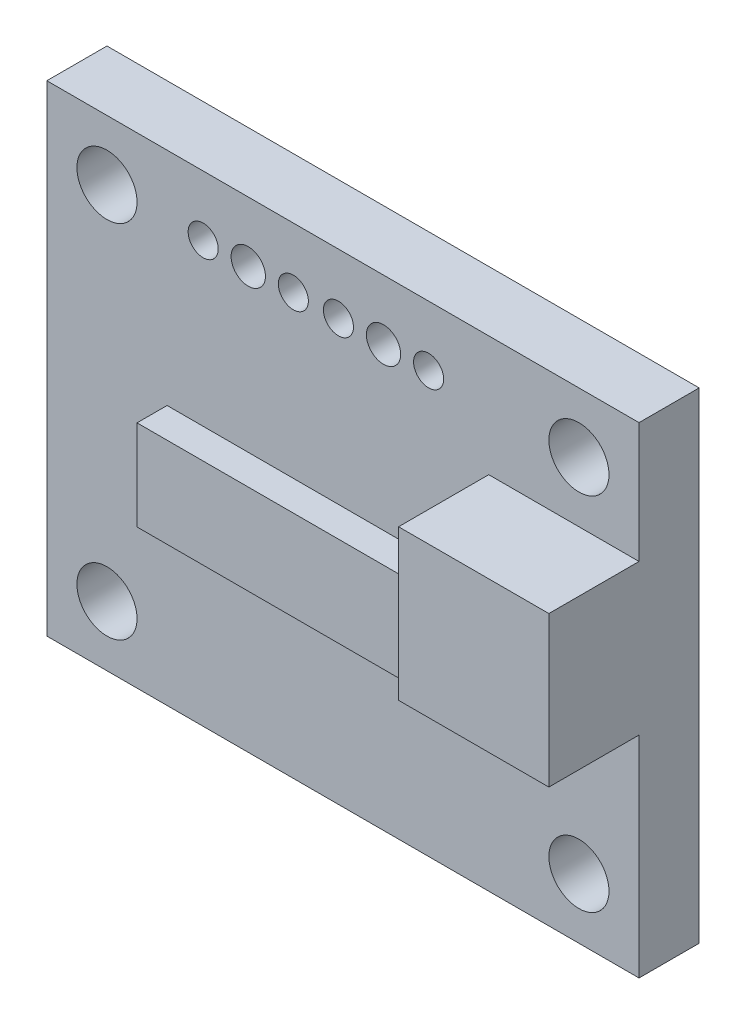
from build123d import *

# Parameters (mm, degrees)
SKETCH1_R           = 1
SKETCH1_W           = 10
SKETCH1_H           = 3
SKETCH1_R_2         = 0.5
SKETCH1_R_3         = 0.5706303
BOSS_EXTRUDE1_DEPTH = 2
SKETCH1_3_W         = 5
SKETCH1_3_H         = 5
BOSS_EXTRUDE2_DEPTH = 5
SKETCH1_4_W         = 10
SKETCH1_4_H         = 3
BOSS_EXTRUDE3_DEPTH = 3


with BuildPart() as part:
    # Sketch1 → Boss-Extrude1 (new body)
    with BuildSketch(Plane.XY):
        Polygon((3.5, 7.35633001), (-16.2, 7.35633001), (-16.2, -8.64366999), (-11.2, -8.64366999), (-1.5, -8.64366999), (3.5, -8.64366999), (3.5, -1.64366999), (-1.5, -1.64366999), (-1.5, 3.35633001), (3.5, 3.35633001), align=None)
        with Locations((-14.2, -6.64366999)):
            Circle(SKETCH1_R, mode=Mode.SUBTRACT)
        with Locations((-7.2, -1.5)):
            Rectangle(SKETCH1_W, SKETCH1_H, mode=Mode.SUBTRACT)
        with Locations((1.5, -6.64366999)):
            Circle(SKETCH1_R, mode=Mode.SUBTRACT)
        with Locations((-14.2, 5.35633001)):
            Circle(SKETCH1_R, mode=Mode.SUBTRACT)
        with Locations((-11, 5.35633001)):
            Circle(SKETCH1_R_2, mode=Mode.SUBTRACT)
        with Locations((-9.5, 5.35633001)):
            Circle(SKETCH1_R_3, mode=Mode.SUBTRACT)
        with Locations((-8, 5.35633001)):
            Circle(SKETCH1_R_2, mode=Mode.SUBTRACT)
        with Locations((-6.5, 5.35633001)):
            Circle(SKETCH1_R_2, mode=Mode.SUBTRACT)
        with Locations((-5, 5.35633001)):
            Circle(SKETCH1_R_3, mode=Mode.SUBTRACT)
        with Locations((-3.5, 5.35633001)):
            Circle(SKETCH1_R_2, mode=Mode.SUBTRACT)
        with Locations((1.5, 5.35633001)):
            Circle(SKETCH1_R, mode=Mode.SUBTRACT)
    extrude(amount=BOSS_EXTRUDE1_DEPTH)

    # Sketch1_3 → Boss-Extrude2 (add)
    with BuildSketch(Plane.XY):
        with Locations((1, 0.85633001)):
            Rectangle(SKETCH1_3_W, SKETCH1_3_H)
    extrude(amount=BOSS_EXTRUDE2_DEPTH)

    # Sketch1_4 → Boss-Extrude3 (add)
    with BuildSketch(Plane.XY):
        with Locations((-7.2, -1.5)):
            Rectangle(SKETCH1_4_W, SKETCH1_4_H)
    extrude(amount=BOSS_EXTRUDE3_DEPTH)


solid = part.part
